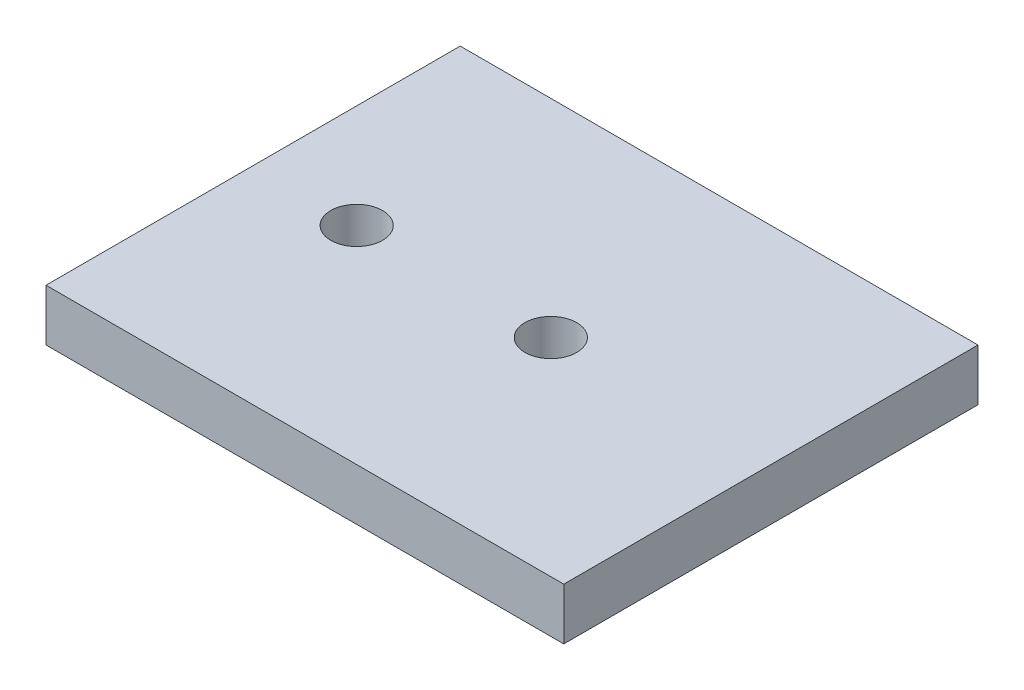
from build123d import *

# Parameters (mm, degrees)
SKETCH2_W           = 127
SKETCH2_H           = 101.6
BOSS_EXTRUDE1_DEPTH = 12.7
SKETCH3_R           = 6.35
CUT_EXTRUDE1_DEPTH  = 13.7


with BuildPart() as part:
    # Sketch2 → Boss-Extrude1 (new body)
    with BuildSketch(Plane(origin=(0, 0, 0), x_dir=(1, 0, 0), z_dir=(0, 1, 0))):
        Rectangle(SKETCH2_W, SKETCH2_H)
    extrude(amount=BOSS_EXTRUDE1_DEPTH)

    # Sketch3 → Cut-Extrude1 (cut, through all)
    with BuildSketch(Plane(origin=(0, 12.7, 0), x_dir=(1, 0, 0), z_dir=(0, 1, 0))):
        with Locations((-38.1, 0)):
            Circle(SKETCH3_R)
        with Locations((9.525, 0)):
            Circle(SKETCH3_R)
    extrude(amount=-CUT_EXTRUDE1_DEPTH, mode=Mode.SUBTRACT)


solid = part.part
